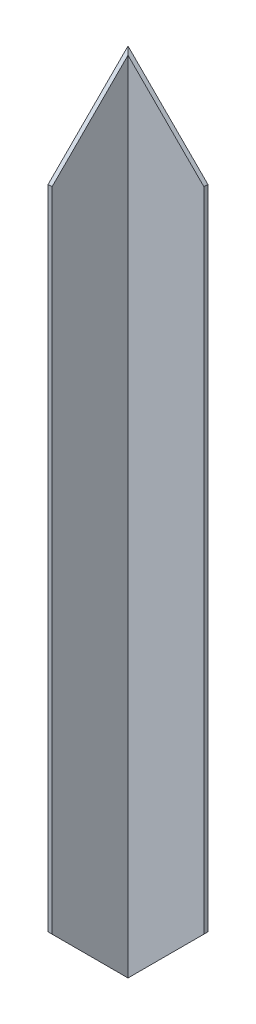
from build123d import *

# Parameters (mm, degrees)
BOSS_EXTRU_1_DEPTH      = 404
ENL_V_MAT_EXTRU_1_DEPTH = 590
ENL_V_MAT_EXTRU_2_DEPTH = 590
ENL_V_MAT_EXTRU_3_DEPTH = 41
ENL_V_MAT_EXTRU_4_DEPTH = 41


with BuildPart() as part:
    # Esquisse1 → Boss.-Extru.1 (new body)
    with BuildSketch(Plane(origin=(0, 0, 0), x_dir=(1, 0, 0), z_dir=(0, 1, 0))):
        Polygon((-20, 20.113636364), (20, 20.113636364), (20, 18.113636364), (-18, 18.113636364), (-18, -19.886363636), (-20, -19.886363636), align=None)
    extrude(amount=BOSS_EXTRU_1_DEPTH)

    # Esquisse2 → Enlèv. mat.-Extru.1 (cut)
    with BuildSketch(Plane(origin=(0, 0, -20.113636364), x_dir=(-1, 0, 0), z_dir=(0, 0, -1))):
        Polygon((20, 0), (-20, 40), (-20, 0), align=None)
    extrude(amount=-ENL_V_MAT_EXTRU_1_DEPTH, mode=Mode.SUBTRACT)

    # Esquisse3 → Enlèv. mat.-Extru.2 (cut)
    with BuildSketch(Plane.ZY.offset(20)):
        Polygon((-20.113636364, 0), (19.886363636, 40), (19.886363636, 0), align=None)
    extrude(amount=-ENL_V_MAT_EXTRU_2_DEPTH, mode=Mode.SUBTRACT)

    # Esquisse4 → Enlèv. mat.-Extru.3 (cut, through all)
    with BuildSketch(Plane.ZY.offset(20)):
        Polygon((-20.113636364, 404), (19.886363636, 364), (19.886363636, 404), align=None)
    extrude(amount=-ENL_V_MAT_EXTRU_3_DEPTH, mode=Mode.SUBTRACT)

    # Esquisse5 → Enlèv. mat.-Extru.4 (cut, through all)
    with BuildSketch(Plane(origin=(0, 0, -20.113636364), x_dir=(-1, 0, 0), z_dir=(0, 0, -1))):
        Polygon((20, 404), (-20, 364), (-20, 404), align=None)
    extrude(amount=-ENL_V_MAT_EXTRU_4_DEPTH, mode=Mode.SUBTRACT)


solid = part.part
